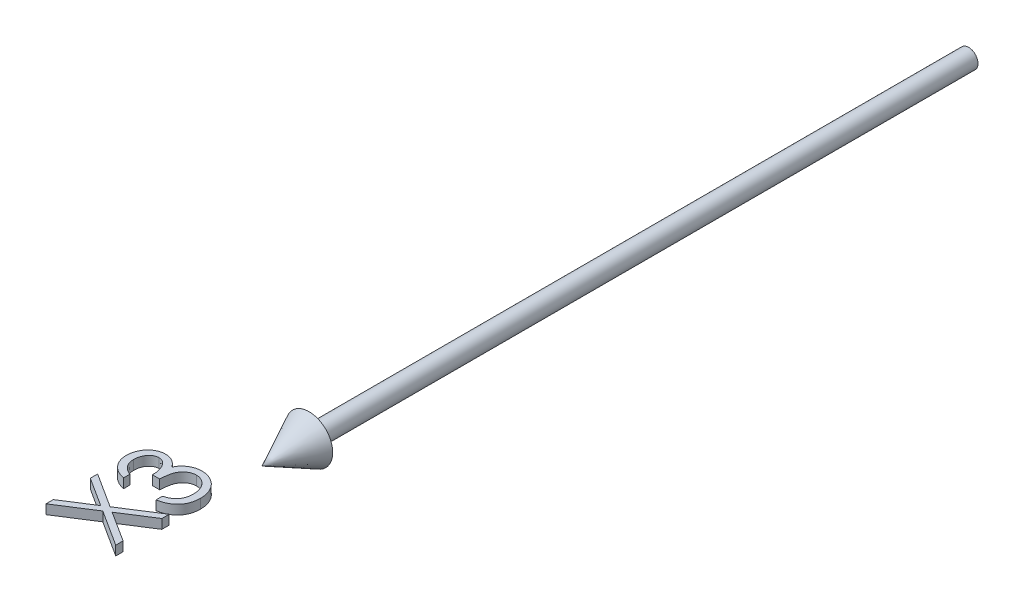
from build123d import *

# Parameters (mm, degrees)
BOSS_EXTRUDE1_DEPTH        = 1
BOSS_EXTRUDE1_DEPTH_BACK   = 1
BOSS_EXTRUDE1_2_DEPTH      = 1
BOSS_EXTRUDE1_2_DEPTH_BACK = 1


with BuildPart() as part:
    # Sketch2 → Revolve1 (revolve)
    with BuildSketch(Plane(origin=(0, 0, 0), x_dir=(1, 0, 0), z_dir=(0, 1, 0))):
        Polygon((0, -150), (5, -140), (2, -140), (2, 0), (0, 0), align=None)
    revolve(axis=Axis((0, 0, -41.949952025), (0, 0, 1)))


with BuildPart() as body_2:
    # Sketch3 → Boss-Extrude1 (new, two sides: drawn at the far end of the back side and taken through both)
    with BuildSketch(Plane(origin=(0, 0, 0), x_dir=(1, 0, 0), z_dir=(0, 1, 0)).offset(-BOSS_EXTRUDE1_DEPTH_BACK)):
        with BuildLine():
            Line((-11.538461538, -166.538461538), (-11.538461538, -167.884615385))
            add(Edge.make_bspline(
                [(-11.538461538, -167.884615385), (-11.689457898, -167.848145882), (-11.984643431, -167.776850986), (-12.406388835, -167.6281471), (-12.805489641, -167.466150292), (-13.174472814, -167.271625558), (-13.520753826, -167.059445183), (-13.836478645, -166.816347805), (-14.129677068, -166.553548994), (-14.389876658, -166.26287064), (-14.625495497, -165.958033519), (-14.8263886, -165.634742291), (-14.999206398, -165.299501318), (-15.141578821, -164.949987891), (-15.248831065, -164.585161441), (-15.326645946, -164.208320198), (-15.377179293, -163.818476626), (-15.382111134, -163.553844095), (-15.384615385, -163.419471154)],
                knots=[0, 0, 0, 0, 1.162005537, 2.271625781, 3.343758855, 4.383309926, 5.390229558, 6.379919256, 7.361854164, 8.333198761, 9.295911338, 10.242430842, 11.177959212, 12.116337295, 13.062827104, 14.020064771, 14.994644689, 16, 16, 16, 16], degree=3))
            add(Edge.make_bspline(
                [(-15.384615385, -163.419471154), (-15.378704398, -163.223687974), (-15.36701136, -162.836392212), (-15.260235204, -162.267407725), (-15.091270351, -161.718721358), (-14.85781152, -161.196338867), (-14.569865892, -160.711117013), (-14.227159877, -160.279390499), (-13.836305728, -159.907011167), (-13.404594738, -159.594606691), (-12.943213983, -159.349999552), (-12.468356167, -159.16962938), (-11.981147718, -159.059822176), (-11.65218795, -159.045591218), (-11.487379808, -159.038461538)],
                knots=[0, 0, 0, 0, 1.083050992, 2.142477498, 3.193116406, 4.255571735, 5.30263384, 6.308962982, 7.297363603, 8.282367274, 9.249857812, 10.179914175, 11.08814088, 12, 12, 12, 12], degree=3))
            add(Edge.make_bspline(
                [(-11.487379808, -159.038461538), (-11.328779259, -159.043448357), (-11.018422597, -159.053206788), (-10.565330466, -159.136065526), (-10.138295037, -159.275506652), (-9.735518627, -159.468662778), (-9.359555028, -159.718697993), (-9.009558353, -160.02158098), (-8.683976247, -160.37944953), (-8.49746422, -160.650644979), (-8.401442308, -160.790264423)],
                knots=[0, 0, 0, 0, 1.024540389, 2.004866551, 2.965041327, 3.920577974, 4.882998113, 5.874504559, 6.905732034, 8, 8, 8, 8], degree=3))
            add(Edge.make_bspline(
                [(-8.401442308, -160.790264423), (-8.324672319, -160.630496374), (-8.172322261, -160.313436651), (-7.868793148, -159.885630555), (-7.526944029, -159.491351328), (-7.257191084, -159.274053688), (-7.121394231, -159.164663462)],
                knots=[0, 0, 0, 0, 1.015663554, 2.015584519, 3.001021554, 4, 4, 4, 4], degree=3))
            add(Edge.make_bspline(
                [(-7.121394231, -159.164663462), (-7.022575295, -159.09248628), (-6.826555653, -158.949313868), (-6.511399542, -158.772590152), (-6.192750302, -158.612265377), (-5.862067133, -158.487335865), (-5.523182789, -158.390590722), (-5.175515377, -158.321436298), (-4.818780996, -158.278475694), (-4.577441795, -158.272323328), (-4.456129808, -158.269230769)],
                knots=[0, 0, 0, 0, 1.025084078, 2.033381695, 3.024893161, 4.013698104, 4.991890475, 5.976764909, 6.982997093, 8, 8, 8, 8], degree=3))
            add(Edge.make_bspline(
                [(-4.456129808, -158.269230769), (-4.246089219, -158.27692265), (-3.826996497, -158.292270213), (-3.207803012, -158.429413906), (-2.602613657, -158.642106903), (-2.023479045, -158.943814934), (-1.482141234, -159.313175531), (-0.994212159, -159.74774451), (-0.581382488, -160.253734571), (-0.232273507, -160.812807752), (0.044193129, -161.421117542), (0.243460232, -162.069095877), (0.362980472, -162.752992823), (0.37732164, -163.220675759), (0.384615385, -163.458533654)],
                knots=[0, 0, 0, 0, 0.955697303, 1.906897079, 2.875188111, 3.870982192, 4.871999088, 5.854111427, 6.836107184, 7.836239895, 8.848948182, 9.870701427, 10.917064451, 12, 12, 12, 12], degree=3))
            add(Edge.make_bspline(
                [(0.384615385, -163.458533654), (0.380862016, -163.618891989), (0.37347664, -163.93442372), (0.323887695, -164.398468191), (0.23085521, -164.840481694), (0.113853984, -165.264756356), (-0.047913319, -165.664888841), (-0.240769913, -166.04663468), (-0.469661352, -166.40832055), (-0.734972564, -166.747798516), (-1.031948792, -167.064705889), (-1.365523642, -167.350968918), (-1.72947145, -167.609754802), (-2.127065987, -167.839419246), (-2.557193647, -168.040928817), (-3.02157803, -168.209947017), (-3.516619024, -168.357520782), (-3.861508239, -168.426266764), (-4.038461538, -168.461538462)],
                knots=[0, 0, 0, 0, 1.048603596, 2.063302207, 3.045874044, 3.999447474, 4.937100059, 5.862643889, 6.7929026, 7.7308982, 8.676022965, 9.627908155, 10.600123445, 11.591992905, 12.626222643, 13.701663232, 14.820785756, 16, 16, 16, 16], degree=3))
            Line((-4.038461538, -168.461538462), (-4.038461538, -167.115384615))
            add(Edge.make_bspline(
                [(-4.038461538, -167.115384615), (-3.922965767, -167.080313366), (-3.69831646, -167.012096741), (-3.375000865, -166.895978321), (-3.078609208, -166.763685726), (-2.806967257, -166.621766189), (-2.557399817, -166.472715706), (-2.336506093, -166.305937455), (-2.134583798, -166.133783976), (-2.020821175, -166.004015319), (-1.965144231, -165.940504808)],
                knots=[0, 0, 0, 0, 1.198163088, 2.33053128, 3.407730985, 4.417276592, 5.372219308, 6.28897303, 7.162600585, 8, 8, 8, 8], degree=3))
            add(Edge.make_bspline(
                [(-1.965144231, -165.940504808), (-1.900420928, -165.856510099), (-1.771174108, -165.688779955), (-1.605766423, -165.415628319), (-1.464181399, -165.127351383), (-1.349095157, -164.82154512), (-1.262707273, -164.498168507), (-1.20052934, -164.158533295), (-1.159482243, -163.802082229), (-1.155752252, -163.558811341), (-1.153846154, -163.434495192)],
                knots=[0, 0, 0, 0, 0.946083416, 1.889246487, 2.84504177, 3.809995578, 4.801312957, 5.829064617, 6.89060985, 8, 8, 8, 8], degree=3))
            add(Edge.make_bspline(
                [(-1.153846154, -163.434495192), (-1.156485748, -163.294123038), (-1.161647246, -163.019637408), (-1.209114561, -162.619116583), (-1.278244904, -162.238084665), (-1.385014831, -161.880772126), (-1.516932765, -161.542498523), (-1.682568789, -161.228005739), (-1.87690331, -160.933165283), (-2.097785418, -160.661753546), (-2.339591826, -160.417701371), (-2.592504988, -160.202817743), (-2.855458543, -160.020140622), (-3.129907633, -159.87278243), (-3.414715756, -159.756422929), (-3.710682168, -159.677209212), (-4.015384737, -159.62213129), (-4.22250889, -159.617645809), (-4.326923077, -159.615384615)],
                knots=[0, 0, 0, 0, 1.217147791, 2.380027433, 3.494444702, 4.572153297, 5.609568379, 6.639424714, 7.649109417, 8.668170816, 9.669597737, 10.625200337, 11.543417969, 12.441394052, 13.322311151, 14.205496177, 15.095365482, 16, 16, 16, 16], degree=3))
            add(Edge.make_bspline(
                [(-4.326923077, -159.615384615), (-4.466677019, -159.621956851), (-4.745489506, -159.635068621), (-5.155841572, -159.734755822), (-5.5513555, -159.900203171), (-5.926908684, -160.127282793), (-6.270731039, -160.410468297), (-6.579696009, -160.736370997), (-6.834396625, -161.113857116), (-7.010533834, -161.461029339), (-7.130686512, -161.768602365), (-7.210723541, -162.031809251), (-7.278495903, -162.326480991), (-7.341548633, -162.649050879), (-7.395211512, -163.001950431), (-7.439962163, -163.38479515), (-7.475769478, -163.797662704), (-7.491759887, -164.083481986), (-7.5, -164.230769231)],
                knots=[0, 0, 0, 0, 1.070505987, 2.135685285, 3.216438728, 4.346150463, 5.486482244, 6.621737109, 7.7759408, 8.963942283, 9.59839197, 10.305095457, 11.070459627, 11.915156775, 12.823989992, 13.805807174, 14.869297358, 16, 16, 16, 16], degree=3))
            Line((-7.5, -164.230769231), (-9.038461538, -164.230769231))
            add(Edge.make_bspline(
                [(-9.038461538, -164.230769231), (-9.042064611, -164.045259869), (-9.049119676, -163.682019668), (-9.117326452, -163.150013678), (-9.226825148, -162.643448092), (-9.383279881, -162.169604917), (-9.567564659, -161.738547811), (-9.780500635, -161.36306895), (-10.021509768, -161.053052967), (-10.28597768, -160.805261025), (-10.56808108, -160.616921743), (-10.863907269, -160.481473576), (-11.174628999, -160.400746349), (-11.386761814, -160.390011306), (-11.493389423, -160.384615385)],
                knots=[0, 0, 0, 0, 1.322091412, 2.58874672, 3.817242262, 5.011895168, 6.140903042, 7.155122731, 8.080855046, 8.929742606, 9.727943956, 10.488587771, 11.240295418, 12, 12, 12, 12], degree=3))
            add(Edge.make_bspline(
                [(-11.493389423, -160.384615385), (-11.571735651, -160.386352563), (-11.727601755, -160.389808596), (-11.956033083, -160.435125922), (-12.177471239, -160.500093106), (-12.389391452, -160.594417649), (-12.592227451, -160.716629685), (-12.788204331, -160.864041415), (-12.9747898, -161.040854124), (-13.152946463, -161.238886275), (-13.315019721, -161.458172475), (-13.456860642, -161.693597531), (-13.57718553, -161.944206819), (-13.676736425, -162.208395012), (-13.751539479, -162.487393253), (-13.805270808, -162.779787912), (-13.838859005, -163.086165055), (-13.843695316, -163.295186575), (-13.846153846, -163.401442308)],
                knots=[0, 0, 0, 0, 0.884325644, 1.759323928, 2.622595547, 3.489424008, 4.37295195, 5.294616785, 6.255907374, 7.274251867, 8.302369084, 9.333474657, 10.37669385, 11.44084034, 12.520297356, 13.637342342, 14.798947025, 16, 16, 16, 16], degree=3))
            add(Edge.make_bspline(
                [(-13.846153846, -163.401442308), (-13.840190866, -163.572235171), (-13.828543779, -163.905833355), (-13.726530865, -164.386754428), (-13.56376765, -164.833837288), (-13.369483281, -165.17557443), (-13.177695707, -165.427928319), (-13.010199765, -165.608258054), (-12.824059092, -165.785345956), (-12.607808913, -165.947541714), (-12.376094098, -166.111573043), (-12.117135462, -166.260906878), (-11.837688058, -166.406019845), (-11.640135339, -166.493459343), (-11.538461538, -166.538461538)],
                knots=[0, 0, 0, 0, 1.472543308, 2.876219568, 4.221790263, 5.565193594, 6.249813518, 6.953379497, 7.687249741, 8.463570142, 9.283606569, 10.136032583, 11.040678096, 12, 12, 12, 12], degree=3))
        make_face()
    extrude(amount=BOSS_EXTRUDE1_DEPTH + BOSS_EXTRUDE1_DEPTH_BACK)


with BuildPart() as body_3:
    # Sketch3 → Boss-Extrude1 2 (new, two sides: drawn at the far end of the back side and taken through both)
    with BuildSketch(Plane(origin=(0, 0, 0), x_dir=(1, 0, 0), z_dir=(0, 1, 0)).offset(-BOSS_EXTRUDE1_2_DEPTH_BACK)):
        Polygon((-15, -180.865384615), (-15, -179.311899038), (-8.864182692, -175.384615385), (-15, -171.457331731), (-15, -169.903846154), (-7.650240385, -174.606370192), (0, -169.711538462), (0, -171.265024038), (-6.436298077, -175.384615385), (0, -179.504206731), (0, -181.057692308), (-7.650240385, -176.159855769), align=None)
    extrude(amount=BOSS_EXTRUDE1_2_DEPTH + BOSS_EXTRUDE1_2_DEPTH_BACK)


solid = Compound([part.part, body_2.part, body_3.part])
